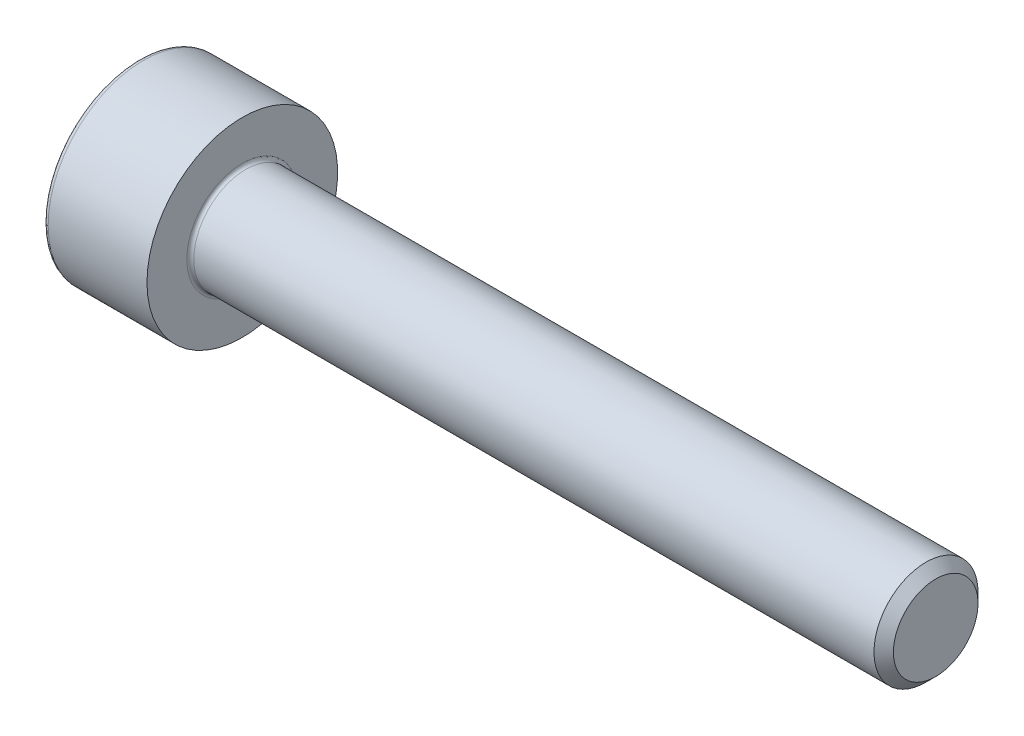
from build123d import *

# Parameters (mm, degrees)
FILLET1_R   = 0.1
FILLET2_R   = 0.15
HEX_2_DEPTH = 1.3


with BuildPart() as part:
    # BodySke → Base-Revolve (revolve)
    with BuildSketch(Plane.XY):
        Polygon((0, 0), (0, 2.75), (3, 2.75), (3, 1.5), (22.7195, 1.5), (23, 1.2195), (23, 0), align=None)
    revolve(axis=Axis((-31.75, 0, 0), (1, 0, 0)))

    # Fillet1
    fillet1_edges = [part.edges().sort_by_distance(p)[0] for p in [
        (3, -1.5, 0),
    ]]
    fillet(fillet1_edges, radius=FILLET1_R)

    # Fillet2
    fillet2_edges = [part.edges().sort_by_distance(p)[0] for p in [
        (0, -2.75, 0),
    ]]
    fillet(fillet2_edges, radius=FILLET2_R)

    # Sketch2 → Hex-PreBroach (revolve, cut)
    with BuildSketch(Plane.XY):
        Polygon((0, 1.28), (1.3, 1.28), (2.039008345, 0), (0, 0), align=None)
    revolve(axis=Axis((0, 0, 0), (1, 0, 0)), mode=Mode.SUBTRACT)

    # Sketch3 → Hex 2 (cut)
    with BuildSketch(Plane(origin=(0, 0, 0), x_dir=(0, 0.5, 0.866025404), z_dir=(-1, 0, 0))):
        Polygon((0.739008345, 1.28), (-0.739008345, 1.28), (-1.478016689, 0), (-0.739008345, -1.28), (0.739008345, -1.28), (1.478016689, 0), align=None)
    extrude(amount=-HEX_2_DEPTH, mode=Mode.SUBTRACT)


solid = part.part
